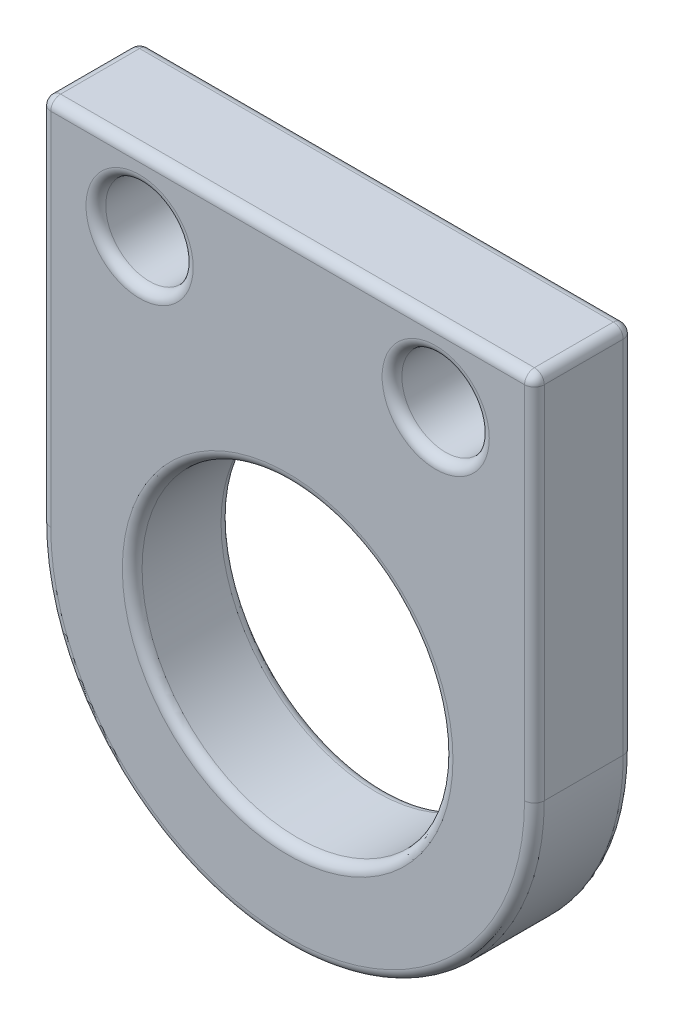
from build123d import *

# Parameters (mm, degrees)
BOSS_EXTRUDE1_DEPTH = 2.54
CUT_EXTRUDE1_REACH  = 4.54
SKETCH3_R           = 4
SKETCH3_R_2         = 1.125
SKETCH3_R_3         = 1.125000036
FILLET1_R           = 0.254


with BuildPart() as part:
    # Sketch2 → Boss-Extrude1 (new body)
    with BuildSketch(Plane(origin=(-2745.911191591, -3464.705285173, -5100.782651944), x_dir=(1, 0, 0), z_dir=(0, 0, 1))):
        with BuildLine():
            Line((-10.605218936, -4.456275494), (-10.605218936, 5.068724506))
            Line((-10.605218936, 5.068724506), (2.094781064, 5.068724506))
            Line((2.094781064, 5.068724506), (2.094781064, -4.456275494))
            ThreePointArc((2.094781064, -4.456275494), (-4.255218936, -10.806275494), (-10.605218936, -4.456275494))
        make_face()
    extrude(amount=BOSS_EXTRUDE1_DEPTH)

    # Sketch3 → Cut-Extrude1 (cut, up to next)
    with BuildSketch(Plane.XY.offset(-5098.242651944), mode=Mode.PRIVATE) as cut_extrude1_sk1:
        with Locations((-2750.166410527, -3469.161560667)):
            Circle(SKETCH3_R)
    cut_extrude1_tool1 = extrude(cut_extrude1_sk1.sketch, amount=-CUT_EXTRUDE1_REACH, mode=Mode.PRIVATE) & part.part
    add(cut_extrude1_tool1.solids().sort_by_distance((-2750.166411, -3469.161561, -5098.242652))[0], mode=Mode.SUBTRACT)
    # Sketch3 → Cut-Extrude1 (cut, up to next)
    with BuildSketch(Plane.XY.offset(-5098.242651944), mode=Mode.PRIVATE) as cut_extrude1_sk2:
        with Locations((-2746.356410527, -3461.541560667)):
            Circle(SKETCH3_R_2)
    cut_extrude1_tool2 = extrude(cut_extrude1_sk2.sketch, amount=-CUT_EXTRUDE1_REACH, mode=Mode.PRIVATE) & part.part
    add(cut_extrude1_tool2.solids().sort_by_distance((-2746.356411, -3461.541561, -5098.242652))[0], mode=Mode.SUBTRACT)
    # Sketch3 → Cut-Extrude1 (cut, up to next)
    with BuildSketch(Plane.XY.offset(-5098.242651944), mode=Mode.PRIVATE) as cut_extrude1_sk3:
        with Locations((-2753.976410527, -3461.541560667)):
            Circle(SKETCH3_R_3)
    cut_extrude1_tool3 = extrude(cut_extrude1_sk3.sketch, amount=-CUT_EXTRUDE1_REACH, mode=Mode.PRIVATE) & part.part
    add(cut_extrude1_tool3.solids().sort_by_distance((-2753.976411, -3461.541561, -5098.242652))[0], mode=Mode.SUBTRACT)

    # Fillet1
    fillet1_edges = [part.edges().sort_by_distance(p)[0] for p in [
        (-2756.516410527, -3464.399060667, -5098.242651944),
        (-2750.166410527, -3475.511560667, -5098.242651944),
        (-2754.166410527, -3469.161560667, -5098.242651944),
        (-2754.166410527, -3469.161560667, -5100.782651944),
        (-2747.481410527, -3461.541560667, -5098.242651944),
        (-2747.481410527, -3461.541560667, -5100.782651944),
        (-2755.101410563, -3461.541560667, -5098.242651944),
        (-2755.101410563, -3461.541560667, -5100.782651944),
        (-2743.816410527, -3464.399060667, -5098.242651944),
        (-2750.166410527, -3475.511560667, -5100.782651944),
        (-2756.516410527, -3464.399060667, -5100.782651944),
        (-2750.166410527, -3459.636560667, -5100.782651944),
        (-2743.816410527, -3464.399060667, -5100.782651944),
        (-2756.516410527, -3459.636560667, -5099.512651944),
        (-2743.816410527, -3459.636560667, -5099.512651944),
        (-2750.166410527, -3459.636560667, -5098.242651944),
    ]]
    fillet(fillet1_edges, radius=FILLET1_R)


solid = part.part
